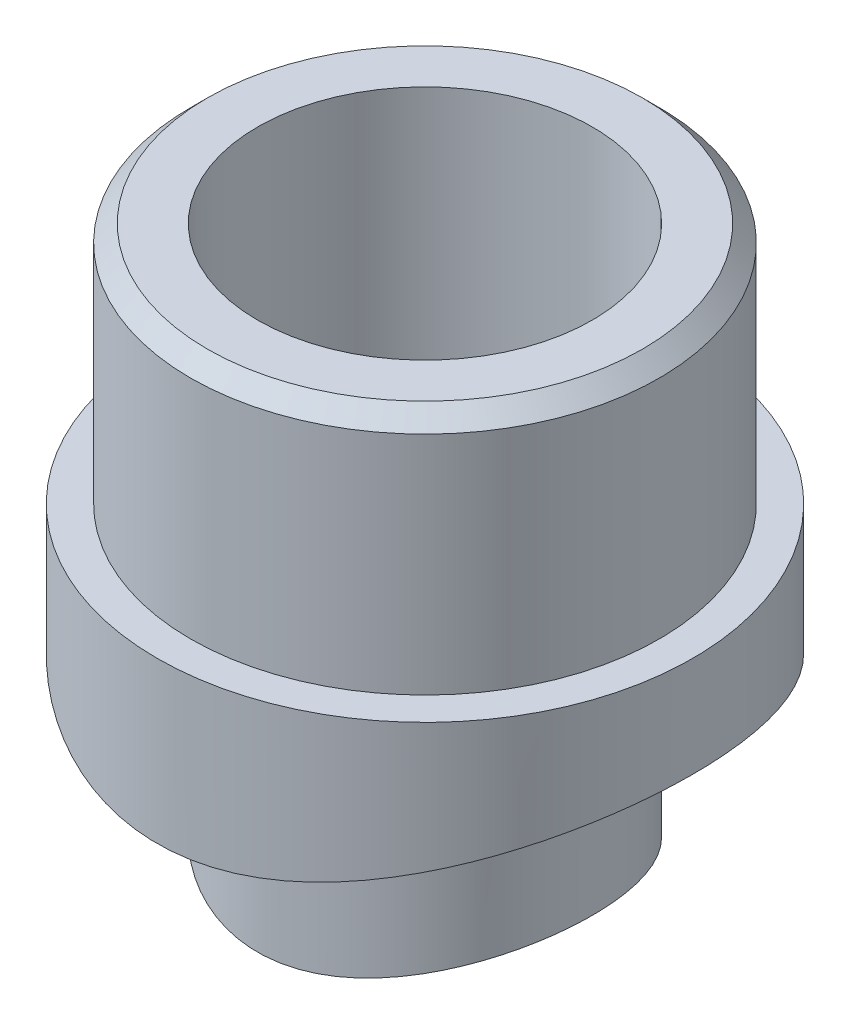
from build123d import *

# Parameters (mm, degrees)
SKETCH1_R               = 16
SKETCH1_R_2             = 6.6
BOSS_EXTRUDE1_DEPTH     = 43.5
SKETCH2_R               = 14
SKETCH2_R_2             = 10
BOSS_EXTRUDE2_DEPTH     = 14.5
SKETCH3_R               = 37.5
CUT_EXTRUDE1_DEPTH      = 17
CUT_EXTRUDE1_DEPTH_BACK = 17
BOSS_EXTRUDE3_REACH     = 60
SKETCH4_R               = 10
SKETCH4_R_2             = 6.6
SKETCH5_R               = 27.2
CUT_EXTRUDE2_DEPTH      = 17.0000001
CUT_EXTRUDE2_DEPTH_BACK = 17.0000001
CHAMFER1_SIZE           = 1


with BuildPart() as part:
    # Sketch1 → Boss-Extrude1 (new body)
    with BuildSketch(Plane(origin=(0, 0, 0), x_dir=(1, 0, 0), z_dir=(0, 1, 0))):
        Circle(SKETCH1_R)
        Circle(SKETCH1_R_2, mode=Mode.SUBTRACT)
    extrude(amount=BOSS_EXTRUDE1_DEPTH)

    # Sketch2 → Boss-Extrude2 (add)
    with BuildSketch(Plane(origin=(0, 43.5, 0), x_dir=(1, 0, 0), z_dir=(0, 1, 0))):
        Circle(SKETCH2_R)
        Circle(SKETCH2_R_2, mode=Mode.SUBTRACT)
    extrude(amount=BOSS_EXTRUDE2_DEPTH)

    # Sketch3 → Cut-Extrude1 (cut, two sides)
    with BuildSketch(Plane(origin=(0, 0, 0), x_dir=(0, 0, -1), z_dir=(1, 0, 0))) as cut_extrude1_sk:
        Circle(SKETCH3_R)
    extrude(amount=CUT_EXTRUDE1_DEPTH, mode=Mode.SUBTRACT)
    extrude(cut_extrude1_sk.sketch, amount=-CUT_EXTRUDE1_DEPTH_BACK, mode=Mode.SUBTRACT)

    # Sketch4 → Boss-Extrude3 (add, up to next)
    with BuildSketch(Plane(origin=(0, 0, 0), x_dir=(1, 0, 0), z_dir=(0, 1, 0)), mode=Mode.PRIVATE) as boss_extrude3_sk1:
        Circle(SKETCH4_R)
        Circle(SKETCH4_R_2, mode=Mode.SUBTRACT)
    boss_extrude3_tool1 = extrude(boss_extrude3_sk1.sketch, amount=BOSS_EXTRUDE3_REACH, mode=Mode.PRIVATE) - part.part
    add(boss_extrude3_tool1.solids().sort_by_distance((-9.717157, 0, 0))[0])

    # Sketch5 → Cut-Extrude2 (cut, two sides)
    with BuildSketch(Plane(origin=(0, 0, 0), x_dir=(0, 0, -1), z_dir=(1, 0, 0))) as cut_extrude2_sk:
        Circle(SKETCH5_R)
    extrude(amount=CUT_EXTRUDE2_DEPTH, mode=Mode.SUBTRACT)
    extrude(cut_extrude2_sk.sketch, amount=-CUT_EXTRUDE2_DEPTH_BACK, mode=Mode.SUBTRACT)

    # Chamfer1
    chamfer1_edges = [part.edges().sort_by_distance(p)[0] for p in [
        (-14, 58, 0),
    ]]
    chamfer(chamfer1_edges, length=CHAMFER1_SIZE)


solid = part.part
